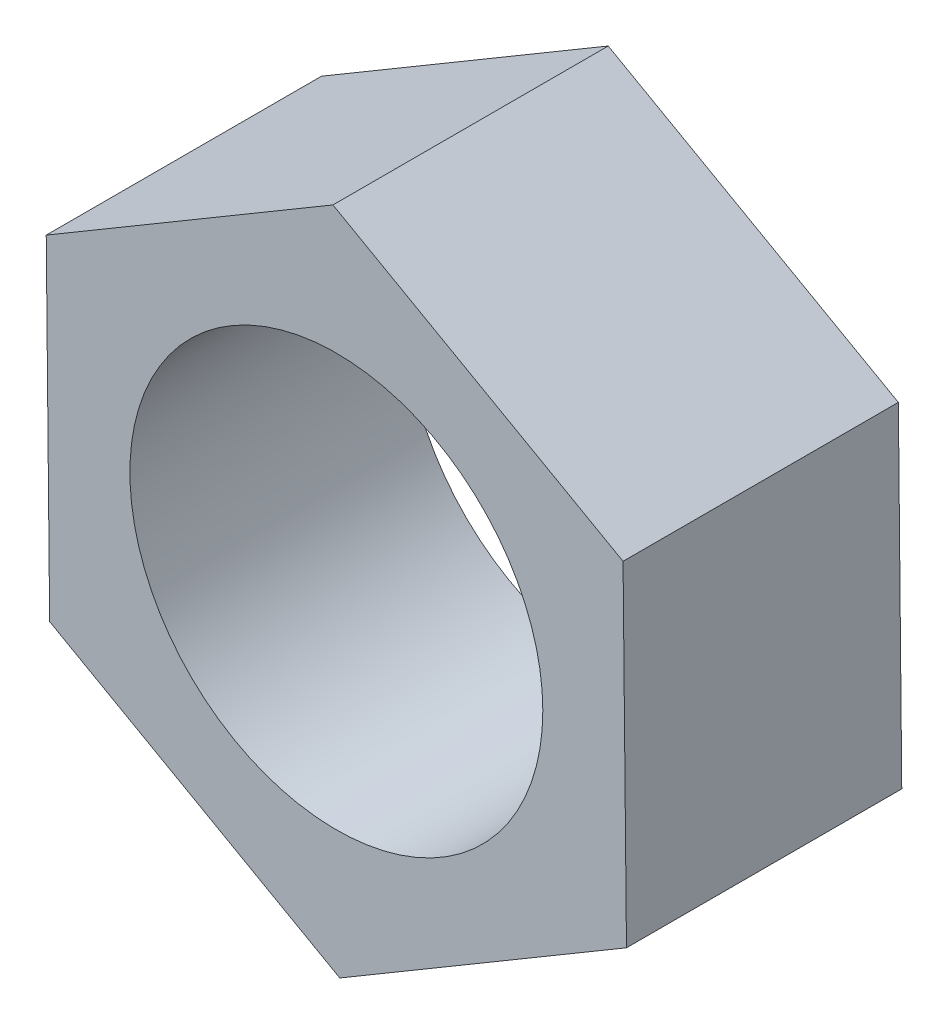
from build123d import *

# Parameters (mm, degrees)
SKETCH_1_R      = 1.5
EXTRUDE_1_DEPTH = 2


with BuildPart() as part:
    # 草图1 → 凸台-拉伸1 (new body)
    with BuildSketch(Plane.XY):
        Polygon((2.082918695, 1.231296777), (-0.024874941, 2.419508893), (-2.107793636, 1.188212115), (-2.082918695, -1.231296777), (0.024874941, -2.419508893), (2.107793636, -1.188212115), align=None)
        Circle(SKETCH_1_R, mode=Mode.SUBTRACT)
    extrude(amount=EXTRUDE_1_DEPTH)


solid = part.part
